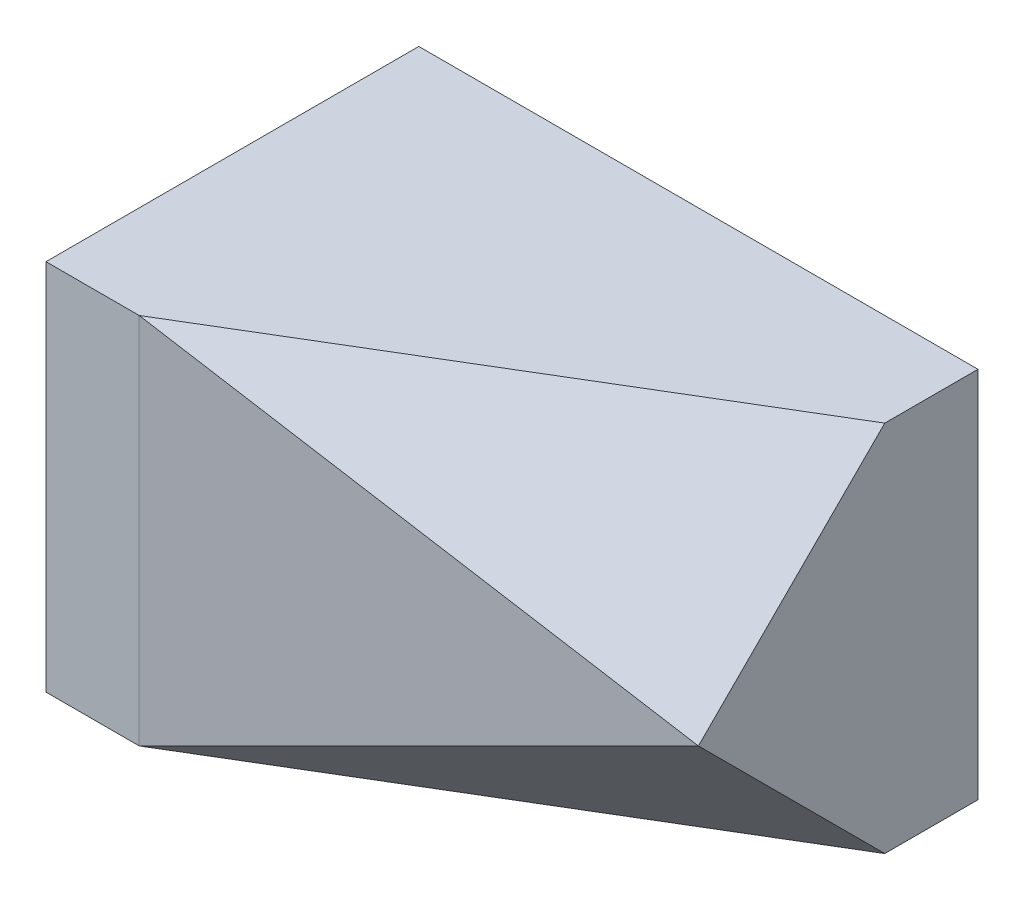
from build123d import *

# Parameters (mm, degrees)
SKETCH1_W           = 1270
SKETCH1_H           = 1016
SKETCH1_W_2         = 254
BOSS_EXTRUDE1_DEPTH = 1016


with BuildPart() as part:
    # Sketch1 → Boss-Extrude1 (new body)
    with BuildSketch(Plane.XY):
        with Locations((889, 508)):
            Rectangle(SKETCH1_W, SKETCH1_H)
        with Locations((127, 508)):
            Rectangle(SKETCH1_W_2, SKETCH1_H)
    extrude(amount=BOSS_EXTRUDE1_DEPTH)

    # SurfaceCut2
    split(bisect_by=Plane(origin=(555.355932203, 925.593220339, 925.593220339), x_dir=(-0.9205746178983233, 0.27617238536949706, 0.27617238536949706), z_dir=(-0.3905667329424717, -0.6509445549041193, -0.6509445549041194)), keep=Keep.TOP)

    # SurfaceCut3
    split(bisect_by=Plane(origin=(297.050847458, -495.084745763, 495.084745763), x_dir=(-0.9205746178983234, -0.27617238536949706, 0.2761723853694971), z_dir=(-0.39056673294247174, 0.6509445549041194, -0.6509445549041194)), keep=Keep.TOP)

    # SurfaceCut4
    split(bisect_by=Plane(origin=(205.153846154, 0, 1025.769230769), x_dir=(-0.9805806756909202, 0, 0.196116135138184), z_dir=(-0.196116135138184, 0, -0.9805806756909202)), keep=Keep.TOP)


solid = part.part
